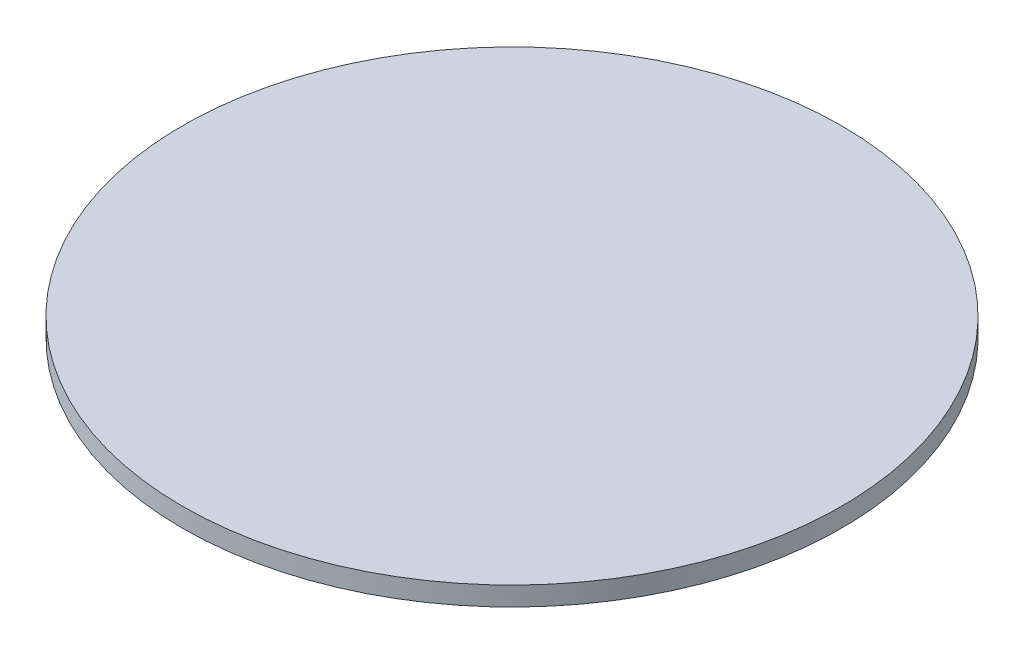
from build123d import *

# Parameters (mm, degrees)
SKETCH1_R           = 17.3
BOSS_EXTRUDE1_DEPTH = 1


with BuildPart() as part:
    # Sketch1 → Boss-Extrude1 (new body)
    with BuildSketch(Plane(origin=(0, 0, 0), x_dir=(1, 0, 0), z_dir=(0, 1, 0))):
        Circle(SKETCH1_R)
    extrude(amount=BOSS_EXTRUDE1_DEPTH)


solid = part.part
